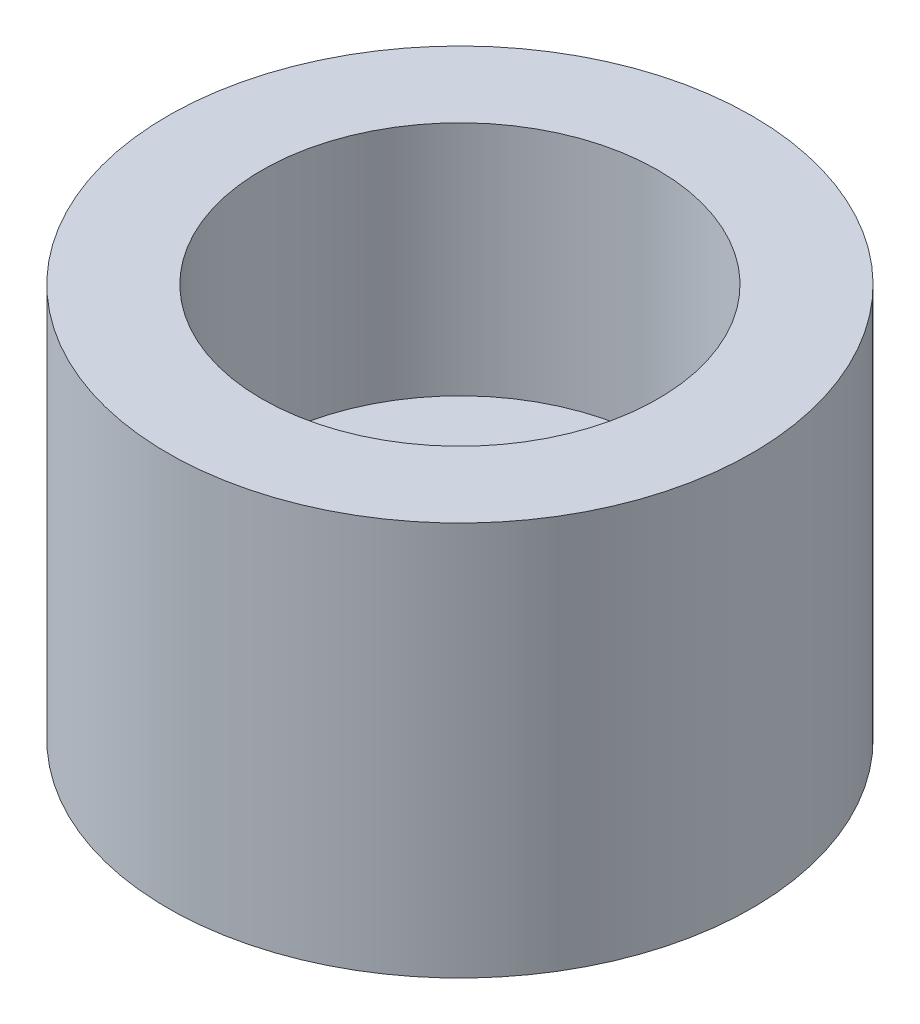
from build123d import *


with BuildPart() as part:
    # Sketch2 → Revolve1 (revolve)
    with BuildSketch(Plane.XY):
        Polygon((2.38125, -0.9525), (2.38125, -4.7625), (7.0612, -4.7625), (7.0612, 4.7625), (4.7879, 4.7625), (4.7879, -0.9525), align=None)
    revolve(axis=Axis((0, 0, 0), (0, 1, 0)))


solid = part.part
